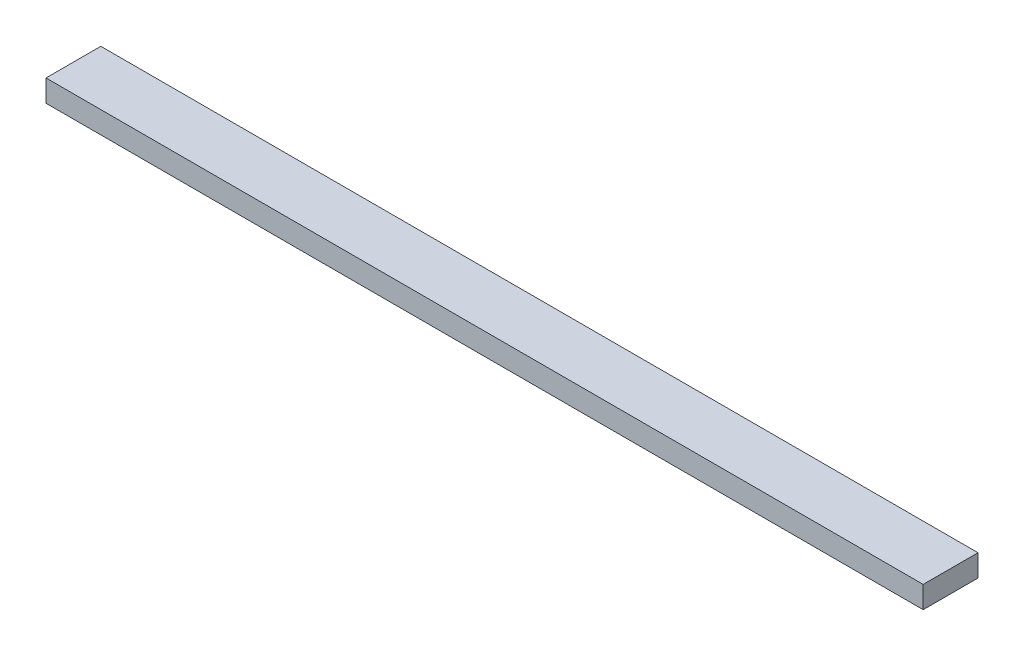
from build123d import *

# Parameters (mm, degrees)
SKETCH_1_W      = 25
SKETCH_1_H      = 10
EXTRUDE_1_DEPTH = 400


with BuildPart() as part:
    # Эскиз1 → Бобышка-Вытянуть1 (new body)
    with BuildSketch(Plane(origin=(0, 0, 0), x_dir=(0, 0, -1), z_dir=(1, 0, 0))):
        with Locations((12.5, 5)):
            Rectangle(SKETCH_1_W, SKETCH_1_H)
    extrude(amount=EXTRUDE_1_DEPTH)


solid = part.part
